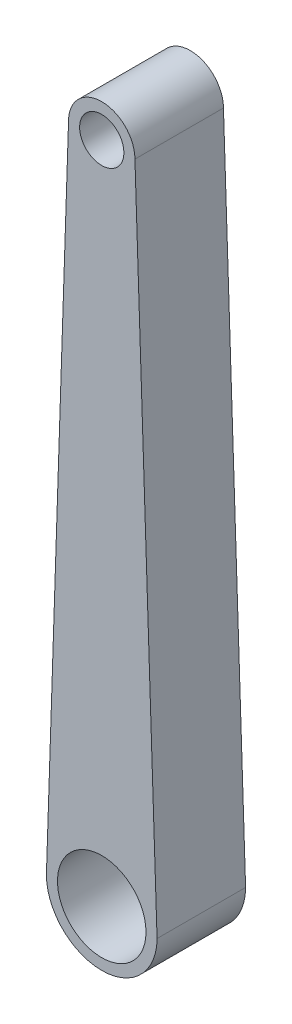
from build123d import *

# Parameters (mm, degrees)
SKETCH1_R           = 20
SKETCH1_R_2         = 10
BOSS_EXTRUDE1_DEPTH = 40


with BuildPart() as part:
    # Sketch1 → Boss-Extrude1 (new body)
    with BuildSketch(Plane.XY):
        with BuildLine():
            Line((-15, 245.227509479), (-25, -54.772490521))
            ThreePointArc((-25, -54.772490521), (0, -79.772490521), (25, -54.772490521))
            Line((25, -54.772490521), (15, 245.227509479))
            ThreePointArc((15, 245.227509479), (0, 260.227509479), (-15, 245.227509479))
        make_face()
        with Locations((0, -54.772490521)):
            Circle(SKETCH1_R, mode=Mode.SUBTRACT)
        with Locations((0, 245.227509479)):
            Circle(SKETCH1_R_2, mode=Mode.SUBTRACT)
    extrude(amount=BOSS_EXTRUDE1_DEPTH)


solid = part.part
